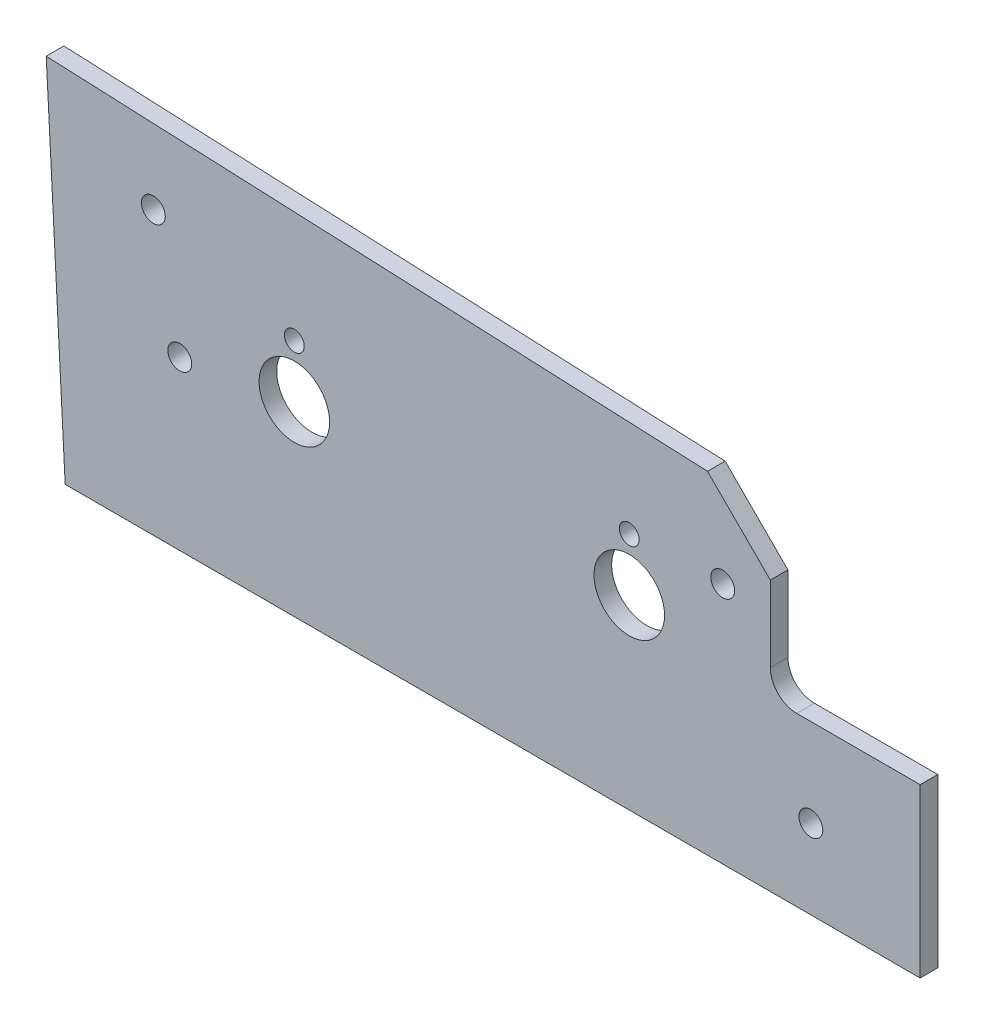
from build123d import *

# Parameters (mm, degrees)
BOSS_EXTRUDE1_DEPTH             = 3.175
F_1_2_0_5_DIAMETER_HOLE1_D      = 12.7
F_9_64_0_14063_DIAMETER_HOLE1_D = 3.572002
F_6_CLEARANCE_HOLE1_D           = 4.3053
F_6_CLEARANCE_HOLE2_D           = 4.3053


with BuildPart() as part:
    # Sketch1 → Boss-Extrude1 (new body)
    with BuildSketch(Plane.XY):
        with BuildLine():
            Line((-26.9875, 34.925), (-26.9875, 48.5775))
            Line((-26.9875, 48.5775), (-38.29743402, 59.88743402))
            Line((-38.29743402, 59.88743402), (-157.398586801, 65.087510963))
            Line((-157.398586801, 65.087510963), (-153.9875, 1.0725e-05))
            Line((-153.9875, 1.0725e-05), (0, 0))
            Line((0, 0), (0, 30.1625))
            Line((0, 30.1625), (-22.225, 30.1625))
            ThreePointArc((-22.225, 30.1625), (-25.592596045, 31.557403955), (-26.9875, 34.925))
        make_face()
    extrude(amount=-BOSS_EXTRUDE1_DEPTH)

    # 1/2 (0.5) Diameter Hole1 (through all)
    with Locations(Plane.XY):
        with Locations((-112.7125, 33.528), (-52.3875, 33.528)):
            Hole(F_1_2_0_5_DIAMETER_HOLE1_D / 2)

    # 9/64 (0.14063) Diameter Hole1 (through all)
    with Locations(Plane.XY):
        with Locations((-112.7125, 43.053), (-52.3875, 43.053)):
            Hole(F_9_64_0_14063_DIAMETER_HOLE1_D / 2)

    # #6 Clearance Hole1 (through all)
    with Locations(Plane.XY):
        with Locations((-133.35, 30.1625), (-35.56, 43.688)):
            Hole(F_6_CLEARANCE_HOLE1_D / 2)

    # #6 Clearance Hole2 (through all)
    with Locations(Plane.XY):
        with Locations((-138.1125, 50.8), (-19.685, 14.2875)):
            Hole(F_6_CLEARANCE_HOLE2_D / 2)


solid = part.part
